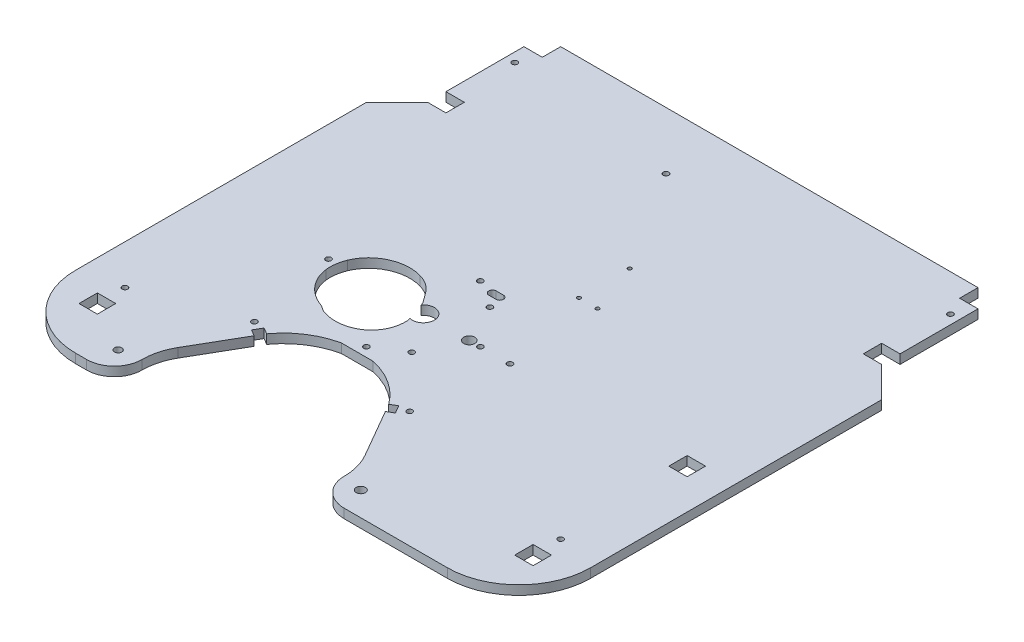
from build123d import *

# Parameters (mm, degrees)
ESQUISSE1_W              = 280.2
ESQUISSE1_H              = 276.282873123
BOSS_EXTRU_1_DEPTH       = 5
ESQUISSE2_R              = 1.5
ENL_V_MAT_EXTRU_2_DEPTH  = 6
ENL_V_MAT_EXTRU_3_DEPTH  = 6
ESQUISSE4_R              = 1
ENL_V_MAT_EXTRU_4_DEPTH  = 6.0000001
ESQUISSE5_R              = 1.5
ESQUISSE5_R_2            = 3
ENL_V_MAT_EXTRU_5_DEPTH  = 6.0000001
ESQUISSE6_R              = 6
ENL_V_MAT_EXTRU_6_DEPTH  = 6.0000001
ENL_V_MAT_EXTRU_7_DEPTH  = 6.0000001
ENL_V_MAT_EXTRU_8_DEPTH  = 6.0000001
ENL_V_MAT_EXTRU_9_DEPTH  = 6.0000001
ESQUISSE11_W             = 10
ESQUISSE11_H             = 10
ENL_V_MAT_EXTRU_11_DEPTH = 6.0000001
ESQUISSE12_R             = 2.5
ESQUISSE12_R_2           = 2
ENL_V_MAT_EXTRU_12_DEPTH = 6.0000001
ESQUISSE13_R             = 1.5
ENL_V_MAT_EXTRU_15_DEPTH = 6.0000001
ESQUISSE14_W             = 17.246829532
ESQUISSE14_H             = 2
BOSS_EXTRU_2_DEPTH       = 5


with BuildPart() as part:
    # Esquisse1 → Boss.-Extru.1 (new body)
    with BuildSketch(Plane(origin=(0, 0, 0), x_dir=(1, 0, 0), z_dir=(0, 1, 0))):
        with Locations((0, -106.941436562)):
            Rectangle(ESQUISSE1_W, ESQUISSE1_H)
    extrude(amount=BOSS_EXTRU_1_DEPTH)

    # Esquisse2 → Enlèv. mat.-Extru.2 (cut, through all)
    with BuildSketch(Plane(origin=(0, 0, 0), x_dir=(1, 0, 0), z_dir=(0, 1, 0))):
        with Locations((-67.225778058, -181.665063509)):
            Circle(ESQUISSE2_R)
        with Locations((17.225778058, -181.665063509)):
            Circle(ESQUISSE2_R)
        with BuildLine():
            Line((-58.181549424, -184), (-61.645651039, -182))
            Line((-61.645651039, -182), (-64.145651039, -186.330127019))
            Line((-64.145651039, -186.330127019), (-60.681549424, -188.330127019))
            Line((-60.681549424, -188.330127019), (-75.853895909, -214.609402001))
            ThreePointArc((-75.853895909, -214.609402001), (-78.945508514, -222.073215083), (-80, -230.082873123))
            ThreePointArc((-80, -230.082873123), (-84.393398282, -240.68947484), (-95, -245.082873123))
            Line((-95, -245.082873123), (45, -245.082873123))
            ThreePointArc((45, -245.082873123), (34.393398282, -240.68947484), (30, -230.082873123))
            ThreePointArc((30, -230.082873123), (28.945508514, -222.073215083), (25.853895909, -214.609402001))
            Line((25.853895909, -214.609402001), (10.681549424, -188.330127019))
            Line((10.681549424, -188.330127019), (14.145651039, -186.330127019))
            Line((14.145651039, -186.330127019), (11.645651039, -182))
            Line((11.645651039, -182), (8.181549424, -184))
            ThreePointArc((8.181549424, -184), (-25, -167.082873123), (-58.181549424, -184))
        make_face()
    extrude(amount=ENL_V_MAT_EXTRU_2_DEPTH, mode=Mode.SUBTRACT)

    # Esquisse3 → Enlèv. mat.-Extru.3 (cut, through all)
    with BuildSketch(Plane(origin=(0, 5, 0), x_dir=(1, 0, 0), z_dir=(0, 1, 0))):
        with BuildLine():
            Line((-30.219849208, -127.059608278), (-26.108908992, -139.132774718))
            add(Edge.make_bspline(
                [(-26.108908992, -139.132774718), (-25.956950527, -141.563829387), (-26.223293229, -144.068039694), (-26.956586016, -146.390839699)],
                knots=[0, 0, 0, 0, 1, 1, 1, 1], degree=3))
            add(Edge.make_bspline(
                [(-26.956586016, -146.390839699), (-27.222826546, -147.234191105), (-27.88312523, -148.88925138), (-29.202853962, -151.171032895), (-30.876306211, -153.274871062), (-32.153743683, -154.471165295), (-32.834022941, -155.024433994)],
                knots=[0, 0, 0, 0, 0.25, 0.5, 0.75, 1, 1, 1, 1], degree=3))
            add(Edge.make_bspline(
                [(-32.834022941, -155.024433994), (-34.081587302, -156.039073648), (-36.874142369, -157.737451773), (-39.94558254, -158.689126504), (-41.514400633, -158.98831152)],
                knots=[0, 0, 0, 0, 0.5, 1, 1, 1, 1], degree=3))
            add(Edge.make_bspline(
                [(-41.514400633, -158.98831152), (-44.117830219, -159.48480447), (-46.861254472, -159.483236641), (-49.46544784, -158.990765567)],
                knots=[0, 0, 0, 0, 1, 1, 1, 1], degree=3))
            add(Edge.make_bspline(
                [(-49.46544784, -158.990765567), (-49.951989881, -158.898757084), (-50.920132947, -158.680457167), (-51.984284706, -158.361141736), (-52.689516881, -158.115271255), (-53.02787714, -157.990279841), (-53.41118137, -157.84363537), (-53.818530417, -157.638563211), (-54.141104483, -157.453850504), (-54.472608463, -157.253723466), (-54.801717178, -157.036844169), (-54.998319522, -156.900216701), (-55.098918511, -156.830110672)],
                knots=[0, 0, 0, 0, 0.25, 0.5, 0.5625, 0.625, 0.6875, 0.75, 0.8125, 0.875, 0.9375, 1, 1, 1, 1], degree=3))
            add(Edge.make_bspline(
                [(-55.098918511, -156.830110672), (-55.3217742, -156.674805659), (-55.80044899, -156.330817244), (-56.33720149, -156.038962163), (-57.115277657, -155.704741536), (-58.107340958, -155.283125842), (-59.421209195, -154.724809933), (-60.695178463, -154.081458137), (-61.716195871, -153.475135599), (-62.651334353, -152.865127539), (-64.306065222, -151.716905995), (-66.442405301, -149.810998743), (-68.670825307, -147.137088975), (-71.028775534, -143.199014144), (-72.049582873, -139.81170379), (-72.320706317, -137.530983991)],
                knots=[0, 0, 0, 0, 0.03125, 0.0625, 0.09375, 0.125, 0.1875, 0.25, 0.28125, 0.3125, 0.375, 0.5, 0.625, 0.75, 1, 1, 1, 1], degree=3))
            add(Edge.make_bspline(
                [(-72.320706317, -137.530983991), (-72.524001857, -135.820839872), (-72.483207545, -132.329279177), (-71.564689145, -128.979569565), (-70.912675046, -127.389633094)],
                knots=[0, 0, 0, 0, 0.5, 1, 1, 1, 1], degree=3))
            add(Edge.make_bspline(
                [(-70.912675046, -127.389633094), (-70.401010457, -126.141938922), (-69.141056656, -123.747572814), (-66.565670024, -120.533413264), (-63.48146489, -117.931153097), (-59.920786428, -115.900931683), (-56.119376489, -114.563750704), (-52.089522484, -113.899386542), (-48.038217008, -113.946598208), (-45.368489458, -114.452209203), (-44.072416993, -114.824574117)],
                knots=[0, 0, 0, 0, 0.125, 0.25, 0.375, 0.5, 0.625, 0.75, 0.875, 1, 1, 1, 1], degree=3))
            add(Edge.make_bspline(
                [(-44.072416993, -114.824574117), (-43.133455735, -115.094340073), (-41.301452244, -115.753871763), (-39.094030914, -116.938824897), (-37.472293893, -118.085855767), (-36.300624784, -119.101293754), (-35.297198074, -120.192975728), (-34.68526159, -120.940027705), (-34.38448611, -121.321088922)],
                knots=[0, 0, 0, 0, 0.25, 0.5, 0.625, 0.75, 0.875, 1, 1, 1, 1], degree=3))
            add(Edge.make_bspline(
                [(-34.38448611, -121.321088922), (-33.65376, -122.246867115), (-32.598758637, -123.685666452), (-31.241615915, -125.567984762), (-30.544252063, -126.556620952), (-30.219849208, -127.059608278)],
                knots=[0, 0, 0, 0, 0.5, 0.75, 1, 1, 1, 1], degree=3))
        make_face()
    extrude(amount=-ENL_V_MAT_EXTRU_3_DEPTH, mode=Mode.SUBTRACT)

    # Esquisse4 → Enlèv. mat.-Extru.4 (cut, through all)
    with BuildSketch(Plane(origin=(0, 5, 0), x_dir=(1, 0, 0), z_dir=(0, 1, 0))):
        with Locations((19.9, -82.15)):
            Circle(ESQUISSE4_R)
        with Locations((9.8, -82.15)):
            Circle(ESQUISSE4_R)
        with Locations((9.8, -54.55)):
            Circle(ESQUISSE4_R)
    extrude(amount=-ENL_V_MAT_EXTRU_4_DEPTH, mode=Mode.SUBTRACT)

    # Esquisse5 → Enlèv. mat.-Extru.5 (cut, through all)
    with BuildSketch(Plane(origin=(0, 5, 0), x_dir=(1, 0, 0), z_dir=(0, 1, 0))):
        with Locations((22.122359024, -132)):
            Circle(ESQUISSE5_R)
        with Locations((-10.050791121, -153.25)):
            Circle(ESQUISSE5_R)
        with Locations((-25, -163)):
            Circle(ESQUISSE5_R)
        with Locations((-10.050791121, -110.75)):
            Circle(ESQUISSE5_R)
        with Locations((-25, -101)):
            Circle(ESQUISSE5_R)
        with Locations((-76.6, -132)):
            Circle(ESQUISSE5_R)
        with Locations((6, -132)):
            Circle(ESQUISSE5_R)
        with Locations((0, -132)):
            Circle(ESQUISSE5_R_2)
    extrude(amount=-ENL_V_MAT_EXTRU_5_DEPTH, mode=Mode.SUBTRACT)

    # Esquisse6 → Enlèv. mat.-Extru.6 (cut, through all)
    with BuildSketch(Plane(origin=(0, 5, 0), x_dir=(1, 0, 0), z_dir=(0, 1, 0))):
        with Locations((-25, -132)):
            Circle(ESQUISSE6_R)
    extrude(amount=-ENL_V_MAT_EXTRU_6_DEPTH, mode=Mode.SUBTRACT)

    # Esquisse7 → Enlèv. mat.-Extru.7 (cut, through all)
    with BuildSketch(Plane(origin=(0, 5, 0), x_dir=(1, 0, 0), z_dir=(0, 1, 0))):
        with BuildLine():
            Line((-16, -101.4), (-12, -101.4))
            ThreePointArc((-12, -101.4), (-10, -103.4), (-12, -105.4))
            Line((-12, -105.4), (-16, -105.4))
            ThreePointArc((-16, -105.4), (-18, -103.4), (-16, -101.4))
        make_face()
    extrude(amount=-ENL_V_MAT_EXTRU_7_DEPTH, mode=Mode.SUBTRACT)

    # Esquisse8 → Enlèv. mat.-Extru.8 (cut, through all)
    with BuildSketch(Plane(origin=(0, 5, 0), x_dir=(1, 0, 0), z_dir=(0, 1, 0))):
        with BuildLine():
            Line((101.1, -245.082873123), (140.1, -245.082873123))
            Line((140.1, -245.082873123), (140.1, -206.082873123))
            ThreePointArc((140.1, -206.082873123), (128.677164466, -233.660037589), (101.1, -245.082873123))
        make_face()
        with BuildLine():
            Line((-140.1, -245.082873123), (-140.1, -206.082873123))
            ThreePointArc((-140.1, -206.082873123), (-128.677164466, -233.660037589), (-101.1, -245.082873123))
            Line((-101.1, -245.082873123), (-140.1, -245.082873123))
        make_face()
    extrude(amount=-ENL_V_MAT_EXTRU_8_DEPTH, mode=Mode.SUBTRACT)

    # Esquisse9 → Enlèv. mat.-Extru.9 (cut, through all)
    with BuildSketch(Plane(origin=(0, 5, 0), x_dir=(1, 0, 0), z_dir=(0, 1, 0))):
        Polygon((-113.5, 21.2), (-123.5, 21.2), (-123.5, -21.2), (-113.5, -21.2), (-113.5, -31.2), (-123.5, -31.2), (-140.1, -47.8), (-140.1, 31.2), (-113.5, 31.2), align=None)
        Polygon((140.1, 31.2), (113.5, 31.2), (113.5, 21.2), (123.5, 21.2), (123.5, -21.2), (113.5, -21.2), (113.5, -31.2), (123.5, -31.2), (140.1, -47.8), align=None)
    extrude(amount=-ENL_V_MAT_EXTRU_9_DEPTH, mode=Mode.SUBTRACT)

    # Esquisse11 → Enlèv. mat.-Extru.11 (cut, through all)
    with BuildSketch(Plane(origin=(0, 5, 0), x_dir=(1, 0, 0), z_dir=(0, 1, 0))):
        with Locations((-118.5, -215.8)):
            Rectangle(ESQUISSE11_W, ESQUISSE11_H)
        with Locations((118.5, -215.8)):
            Rectangle(ESQUISSE11_W, ESQUISSE11_H)
        with Locations((118.5, -132)):
            Rectangle(ESQUISSE11_W, ESQUISSE11_H)
    extrude(amount=-ENL_V_MAT_EXTRU_11_DEPTH, mode=Mode.SUBTRACT)

    # Esquisse12 → Enlèv. mat.-Extru.12 (cut, through all)
    with BuildSketch(Plane(origin=(0, 5, 0), x_dir=(1, 0, 0), z_dir=(0, 1, 0))):
        with Locations((41, -232)):
            Circle(ESQUISSE12_R)
        with Locations((-91, -232)):
            Circle(ESQUISSE12_R_2)
    extrude(amount=-ENL_V_MAT_EXTRU_12_DEPTH, mode=Mode.SUBTRACT)

    # Esquisse13 → Enlèv. mat.-Extru.15 (cut, through all)
    with BuildSketch(Plane(origin=(0, 5, 0), x_dir=(1, 0, 0), z_dir=(0, 1, 0))):
        with Locations((-118.5, -200.8)):
            Circle(ESQUISSE13_R)
        with Locations((-118.5, 11.2)):
            Circle(ESQUISSE13_R)
        with Locations((118.5, 11.2)):
            Circle(ESQUISSE13_R)
        with Locations((118.5, -200.8)):
            Circle(ESQUISSE13_R)
        with Locations((-25, 0)):
            Circle(ESQUISSE13_R)
    extrude(amount=-ENL_V_MAT_EXTRU_15_DEPTH, mode=Mode.SUBTRACT)

    # Esquisse14 → Boss.-Extru.2 (add)
    with BuildSketch(Plane.XZ):
        with Locations((-25, 167)):
            Rectangle(ESQUISSE14_W, ESQUISSE14_H)
    extrude(amount=-BOSS_EXTRU_2_DEPTH)


solid = part.part
